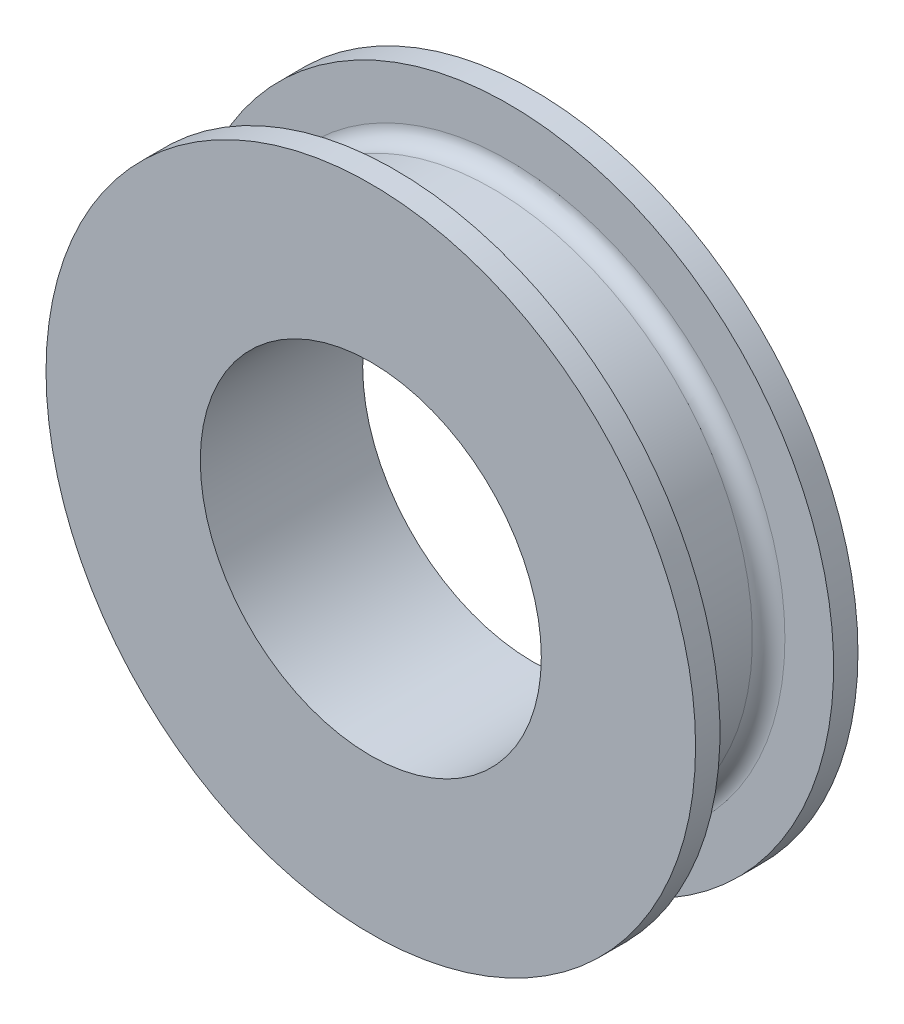
from build123d import *

# Parameters (mm, degrees)
SKETCH_1_R      = 40
SKETCH_1_R_2    = 30
SKETCH_1_R_3    = 21
EXTRUDE_1_DEPTH = 10


with BuildPart() as part:
    # 草图1 → 凸台-拉伸1 (new, symmetric)
    with BuildSketch(Plane.XY):
        Circle(SKETCH_1_R)
        Circle(SKETCH_1_R_2, mode=Mode.SUBTRACT)
        Circle(SKETCH_1_R_2)
        Circle(SKETCH_1_R_3, mode=Mode.SUBTRACT)
    extrude(amount=EXTRUDE_1_DEPTH, both=True)

    # 草图2 → 切除-旋转1 (revolve, cut)
    with BuildSketch(Plane(origin=(0, 0, 0), x_dir=(0, 0, -1), z_dir=(1, 0, 0)), mode=Mode.PRIVATE) as cut_revolve_1_sk:
        with BuildLine():
            Line((-7, 40), (-7, 34))
            ThreePointArc((-7, 34), (-6.414213562, 32.585786438), (-5, 32))
            Line((-5, 32), (5, 32))
            ThreePointArc((5, 32), (6.414213562, 32.585786438), (7, 34))
            Line((7, 34), (7, 40))
            Line((7, 40), (-7, 40))
        make_face()
    revolve(cut_revolve_1_sk.sketch.rotate(Axis((0, 0, 0), (0, 0, 1)), 90), axis=Axis((0, 0, 0), (0, 0, 1)), mode=Mode.SUBTRACT)


solid = part.part
